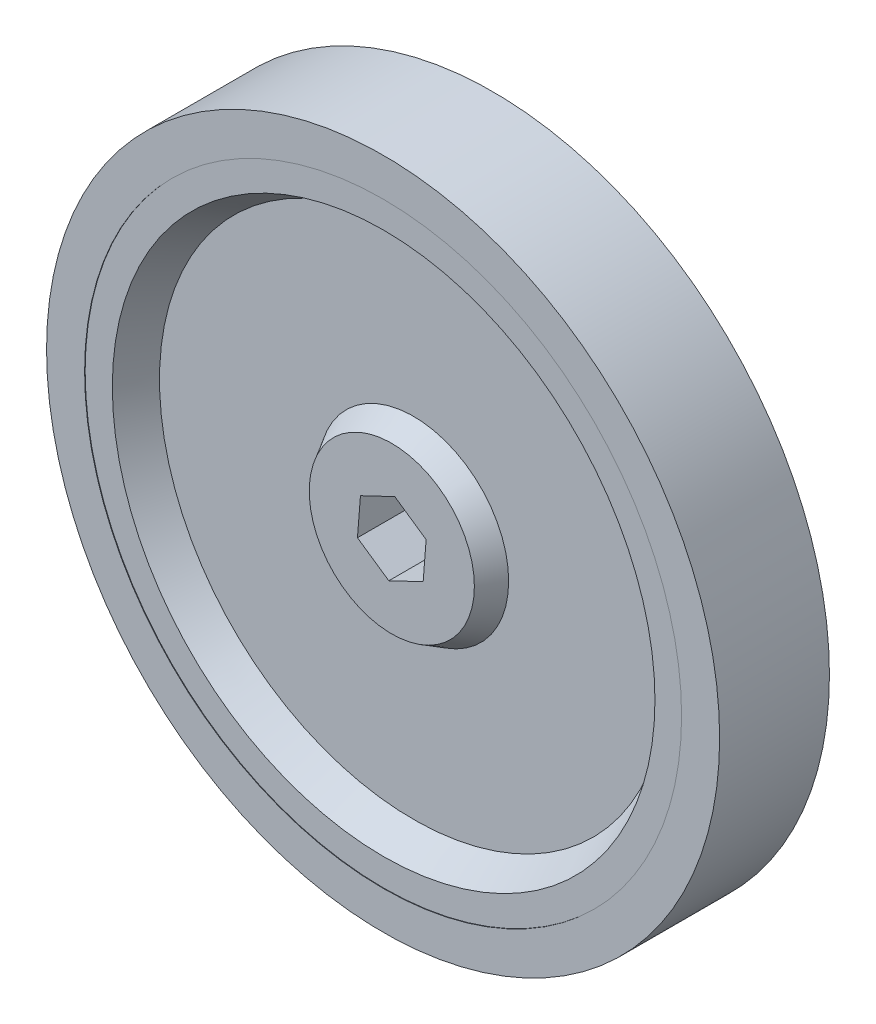
from build123d import *

# Parameters (mm, degrees)
SKETCH1_R           = 61.9125
BOSS_EXTRUDE1_DEPTH = 10
SKETCH4_R           = 49.9125
CUT_EXTRUDE1_DEPTH  = 5.5
CUT_EXTRUDE1_TAPER  = 30
SKETCH5_R           = 49.9125
CUT_EXTRUDE2_DEPTH  = 5.5
CUT_EXTRUDE2_TAPER  = 30
SKETCH6_R           = 17.5
BOSS_EXTRUDE2_DEPTH = 4
BOSS_EXTRUDE2_TAPER = 30
SKETCH9_R           = 17.5
BOSS_EXTRUDE3_DEPTH = 4
BOSS_EXTRUDE3_TAPER = 30
CUT_EXTRUDE4_DEPTH  = 24
SKETCH12_R          = 61.9125
SKETCH12_R_2        = 54.9125
BOSS_EXTRUDE4_DEPTH = 0.1
SKETCH14_R          = 61.9125
SKETCH14_R_2        = 54.9125
BOSS_EXTRUDE5_DEPTH = 0.1


with BuildPart() as part:
    # Sketch1 → Boss-Extrude1 (new body, symmetric)
    with BuildSketch(Plane.XY):
        Circle(SKETCH1_R)
    extrude(amount=BOSS_EXTRUDE1_DEPTH, both=True)

    # Sketch4 → Cut-Extrude1 (cut)
    with BuildSketch(Plane.XY.offset(10)):
        Circle(SKETCH4_R)
    extrude(amount=-CUT_EXTRUDE1_DEPTH, taper=CUT_EXTRUDE1_TAPER, mode=Mode.SUBTRACT)

    # Sketch5 → Cut-Extrude2 (cut)
    with BuildSketch(Plane(origin=(0, 0, -10), x_dir=(-1, 0, 0), z_dir=(0, 0, -1))):
        Circle(SKETCH5_R)
    extrude(amount=-CUT_EXTRUDE2_DEPTH, taper=CUT_EXTRUDE2_TAPER, mode=Mode.SUBTRACT)

    # Sketch6 → Boss-Extrude2 (add)
    with BuildSketch(Plane.XY.offset(4.5)):
        Circle(SKETCH6_R)
    extrude(amount=BOSS_EXTRUDE2_DEPTH, taper=BOSS_EXTRUDE2_TAPER)

    # Sketch9 → Boss-Extrude3 (add)
    with BuildSketch(Plane(origin=(0, 0, -4.5), x_dir=(-1, 0, 0), z_dir=(0, 0, -1))):
        Circle(SKETCH9_R)
    extrude(amount=BOSS_EXTRUDE3_DEPTH, taper=BOSS_EXTRUDE3_TAPER)

    # Sketch10 → Cut-Extrude4 (cut)
    with BuildSketch(Plane(origin=(0, 0, -8.5), x_dir=(-1, 0, 0), z_dir=(0, 0, -1))):
        Polygon((6.317873481, -3.014046231), (5.769177344, 3.964415817), (-0.548696137, 6.978462048), (-6.317873481, 3.014046231), (-5.769177344, -3.964415817), (0.548696137, -6.978462048), align=None)
    extrude(amount=-CUT_EXTRUDE4_DEPTH, mode=Mode.SUBTRACT)

    # Sketch12 → Boss-Extrude4 (add)
    with BuildSketch(Plane.XY.offset(10)):
        Circle(SKETCH12_R)
        Circle(SKETCH12_R_2, mode=Mode.SUBTRACT)
    extrude(amount=BOSS_EXTRUDE4_DEPTH)

    # Sketch14 → Boss-Extrude5 (add)
    with BuildSketch(Plane(origin=(0, 0, -10), x_dir=(-1, 0, 0), z_dir=(0, 0, -1))):
        Circle(SKETCH14_R)
        Circle(SKETCH14_R_2, mode=Mode.SUBTRACT)
    extrude(amount=BOSS_EXTRUDE5_DEPTH)


solid = part.part
